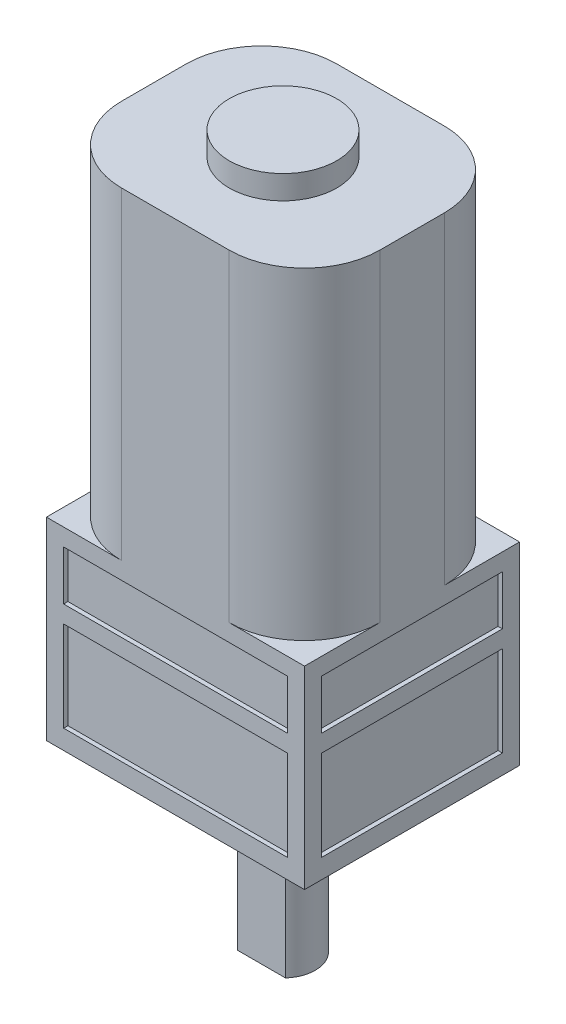
from build123d import *

# Parameters (mm, degrees)
SKETCH1_W           = 12
SKETCH1_H           = 10
BOSS_EXTRUDE1_DEPTH = 9
BOSS_EXTRUDE2_DEPTH = 15
SKETCH3_R           = 2.5
BOSS_EXTRUDE3_DEPTH = 1.1
BOSS_EXTRUDE4_DEPTH = 8
SKETCH5_W           = 10.4
SKETCH5_H           = 2.3
SKETCH5_H_2         = 4.2
CUT_EXTRUDE1_DEPTH  = 0.2
SKETCH6_W           = 8.4
SKETCH6_H           = 2.3
SKETCH6_H_2         = 4.2
CUT_EXTRUDE2_DEPTH  = 0.2


with BuildPart() as part:
    # Sketch1 → Boss-Extrude1 (new body)
    with BuildSketch(Plane(origin=(0, 0, 0), x_dir=(1, 0, 0), z_dir=(0, 1, 0))):
        Rectangle(SKETCH1_W, SKETCH1_H)
    extrude(amount=BOSS_EXTRUDE1_DEPTH)

    # Sketch2 → Boss-Extrude2 (add)
    with BuildSketch(Plane(origin=(0, 9, 0), x_dir=(1, 0, 0), z_dir=(0, 1, 0))):
        with BuildLine():
            Line((-2.5, 5), (2.5, 5))
            ThreePointArc((2.5, 5), (4.974873734, 3.974873734), (6, 1.5))
            Line((6, 1.5), (6, -1.5))
            ThreePointArc((6, -1.5), (4.974873734, -3.974873734), (2.5, -5))
            Line((2.5, -5), (-2.5, -5))
            ThreePointArc((-2.5, -5), (-4.974873734, -3.974873734), (-6, -1.5))
            Line((-6, -1.5), (-6, 1.5))
            ThreePointArc((-6, 1.5), (-4.974873734, 3.974873734), (-2.5, 5))
        make_face()
    extrude(amount=BOSS_EXTRUDE2_DEPTH)

    # Sketch3 → Boss-Extrude3 (add)
    with BuildSketch(Plane(origin=(0, 24, 0), x_dir=(1, 0, 0), z_dir=(0, 1, 0))):
        Circle(SKETCH3_R)
    extrude(amount=BOSS_EXTRUDE3_DEPTH)

    # Sketch4 → Boss-Extrude4 (add)
    with BuildSketch(Plane.XZ):
        with BuildLine():
            Line((-1.118033989, 1), (1.118033989, 1))
            ThreePointArc((1.118033989, 1), (0, -1.5), (-1.118033989, 1))
        make_face()
    extrude(amount=BOSS_EXTRUDE4_DEPTH)

    # Sketch5 → Cut-Extrude1 (cut)
    with BuildSketch(Plane.XY.offset(5)):
        with Locations((0, 7.05)):
            Rectangle(SKETCH5_W, SKETCH5_H)
        with Locations((0, 3)):
            Rectangle(SKETCH5_W, SKETCH5_H_2)
    cut_extrude1 = extrude(amount=-CUT_EXTRUDE1_DEPTH, mode=Mode.SUBTRACT)

    # Mirror1: Cut-Extrude1 across plane
    add(cut_extrude1.mirror(Plane.XY), mode=Mode.SUBTRACT)

    # Sketch6 → Cut-Extrude2 (cut)
    with BuildSketch(Plane.ZY.offset(6)):
        with Locations((0, 7.05)):
            Rectangle(SKETCH6_W, SKETCH6_H)
        with Locations((0, 3)):
            Rectangle(SKETCH6_W, SKETCH6_H_2)
    cut_extrude2 = extrude(amount=-CUT_EXTRUDE2_DEPTH, mode=Mode.SUBTRACT)

    # Mirror2: Cut-Extrude2 across plane
    add(cut_extrude2.mirror(Plane(origin=(0, 0, 0), x_dir=(0, 0, 1), z_dir=(1, 0, 0))), mode=Mode.SUBTRACT)


solid = part.part
